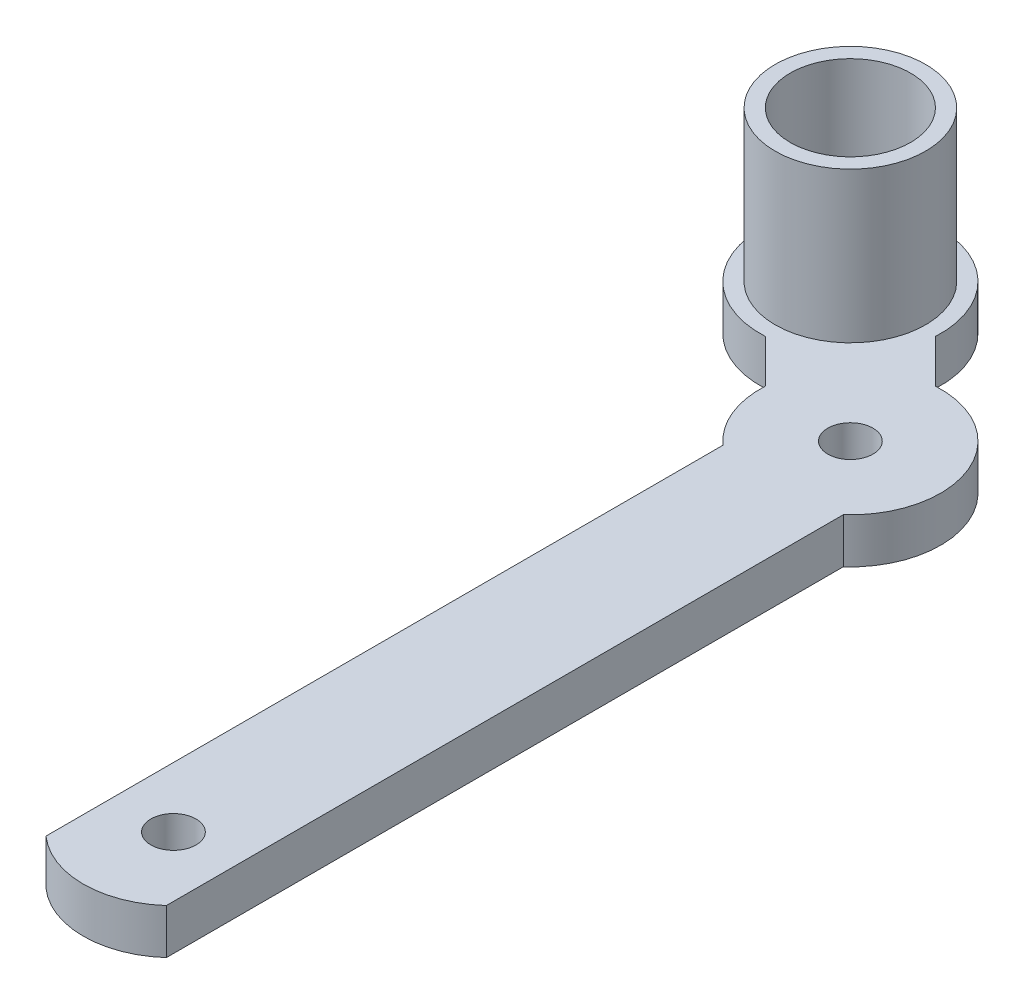
from build123d import *

# Parameters (mm, degrees)
ESQUISSE1_R        = 1.5
ESQUISSE1_R_2      = 4
ESQUISSE1_R_3      = 3
BOSS_EXTRU_1_DEPTH = 3
ESQUISSE2_R        = 5
ESQUISSE2_R_2      = 4
BOSS_EXTRU_2_DEPTH = 10


with BuildPart() as part:
    # Esquisse1 → Boss.-Extru.1 (new body)
    with BuildSketch(Plane(origin=(0, 0, 0), x_dir=(1, 0, 0), z_dir=(0, 1, 0))):
        with BuildLine():
            Line((-4, 4.472135955), (-4, -4.472135955))
            ThreePointArc((-4, -4.472135955), (0, -6), (4, -4.472135955))
            Line((4, -4.472135955), (4, 4.472135955))
            Line((4, 4.472135955), (4, 40.527864045))
            ThreePointArc((4, 40.527864045), (5.543277195, 47.296100594), (-0.333850535, 50.990704785))
            Line((-0.333850535, 50.990704785), (-3.201683371, 53.85853762))
            ThreePointArc((-3.201683371, 53.85853762), (-13.435028843, 58.435028843), (-8.85853762, 48.201683371))
            Line((-8.85853762, 48.201683371), (-5.990704785, 45.333850535))
            ThreePointArc((-5.990704785, 45.333850535), (-5.543277195, 42.703899406), (-4, 40.527864045))
            Line((-4, 40.527864045), (-4, 4.472135955))
        make_face()
        with Locations(Location((0, 0, 0), (0, 0, 270))):
            Circle(ESQUISSE1_R, mode=Mode.SUBTRACT)
        with Locations((-9.192388155, 54.192388155)):
            Circle(ESQUISSE1_R_2, mode=Mode.SUBTRACT)
        with Locations(Location((0, 45, 0), (0, 0, 270))):
            Circle(ESQUISSE1_R, mode=Mode.SUBTRACT)
        with Locations((-9.192388155, 54.192388155)):
            Circle(ESQUISSE1_R_2)
        with Locations(Location((-9.192388155, 54.192388155, 0), (0, 0, 270))):
            Circle(ESQUISSE1_R_3, mode=Mode.SUBTRACT)
    extrude(amount=BOSS_EXTRU_1_DEPTH)

    # Esquisse2 → Boss.-Extru.2 (add)
    with BuildSketch(Plane(origin=(0, 3, 0), x_dir=(1, 0, 0), z_dir=(0, 1, 0))):
        with Locations(Location((-9.192388155, 54.192388155, 0), (0, 0, 270))):
            Circle(ESQUISSE2_R)
        with Locations(Location((-9.192388155, 54.192388155, 0), (0, 0, 270))):
            Circle(ESQUISSE2_R_2, mode=Mode.SUBTRACT)
    extrude(amount=BOSS_EXTRU_2_DEPTH)


solid = part.part
